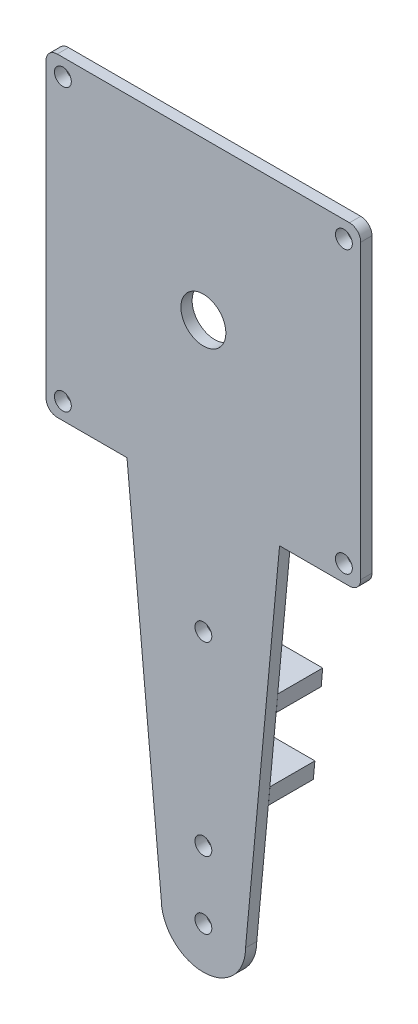
from build123d import *

# Parameters (mm, degrees)
SKETCH2_R           = 1.5
BOSS_EXTRUDE1_DEPTH = 2
SKETCH3_R           = 4
CUT_EXTRUDE1_DEPTH  = 10
BOSS_EXTRUDE2_DEPTH = 8
SKETCH5_R           = 1.5
CUT_EXTRUDE2_DEPTH  = 2
SKETCH6_R           = 7.5
BOSS_EXTRUDE3_DEPTH = 2
SKETCH7_R           = 1.5
CUT_EXTRUDE3_DEPTH  = 2


with BuildPart() as part:
    # Sketch2 → Boss-Extrude1 (new body)
    with BuildSketch(Plane.XY):
        with BuildLine():
            Line((-13.59375, -28), (-26, -28))
            ThreePointArc((-26, -28), (-27.414213562, -27.414213562), (-28, -26))
            Line((-28, -26), (-28, 26))
            ThreePointArc((-28, 26), (-27.414213562, 27.414213562), (-26, 28))
            Line((-26, 28), (26, 28))
            ThreePointArc((26, 28), (27.414213562, 27.414213562), (28, 26))
            Line((28, 26), (28, -26))
            ThreePointArc((28, -26), (27.414213562, -27.414213562), (26, -28))
            Line((26, -28), (13.555660481, -28))
            Line((13.555660481, -28), (7.5, -93))
            Line((7.5, -93), (-7.5, -93))
            Line((-7.5, -93), (-13.59375, -28))
        make_face()
        with Locations((25, 25)):
            Circle(SKETCH2_R, mode=Mode.SUBTRACT)
        with Locations((25, -25)):
            Circle(SKETCH2_R, mode=Mode.SUBTRACT)
        with Locations((-25, -25)):
            Circle(SKETCH2_R, mode=Mode.SUBTRACT)
        with Locations((-25, 25)):
            Circle(SKETCH2_R, mode=Mode.SUBTRACT)
    extrude(amount=BOSS_EXTRUDE1_DEPTH)

    # Sketch3 → Cut-Extrude1 (cut)
    with BuildSketch(Plane.XY.offset(2)):
        Circle(SKETCH3_R)
    extrude(amount=-CUT_EXTRUDE1_DEPTH, mode=Mode.SUBTRACT)

    # Sketch4 → Boss-Extrude2 (add)
    with BuildSketch(Plane(origin=(0, 0, 0), x_dir=(-1, 0, 0), z_dir=(0, 0, -1))):
        Polygon((-11.226560296, -53), (-10.96875, -56), (10.96875, -56), (11.25, -53), align=None)
        Polygon((-9.84375, -68), (-9.5625, -71), (9.5625, -71), (9.84375, -68), align=None)
    extrude(amount=BOSS_EXTRUDE2_DEPTH)

    # Sketch5 → Cut-Extrude2 (cut)
    with BuildSketch(Plane(origin=(0, 0, 0), x_dir=(-1, 0, 0), z_dir=(0, 0, -1))):
        with Locations((0, -48)):
            Circle(SKETCH5_R)
        with Locations((0, -81)):
            Circle(SKETCH5_R)
    extrude(amount=-CUT_EXTRUDE2_DEPTH, mode=Mode.SUBTRACT)

    # Sketch6 → Boss-Extrude3 (add)
    with BuildSketch(Plane(origin=(0, 0, 0), x_dir=(-1, 0, 0), z_dir=(0, 0, -1))):
        with Locations((0, -93)):
            Circle(SKETCH6_R)
    extrude(amount=-BOSS_EXTRUDE3_DEPTH)

    # Sketch7 → Cut-Extrude3 (cut)
    with BuildSketch(Plane.XY.offset(2)):
        with Locations((0, -93)):
            Circle(SKETCH7_R)
    extrude(amount=-CUT_EXTRUDE3_DEPTH, mode=Mode.SUBTRACT)


solid = part.part
